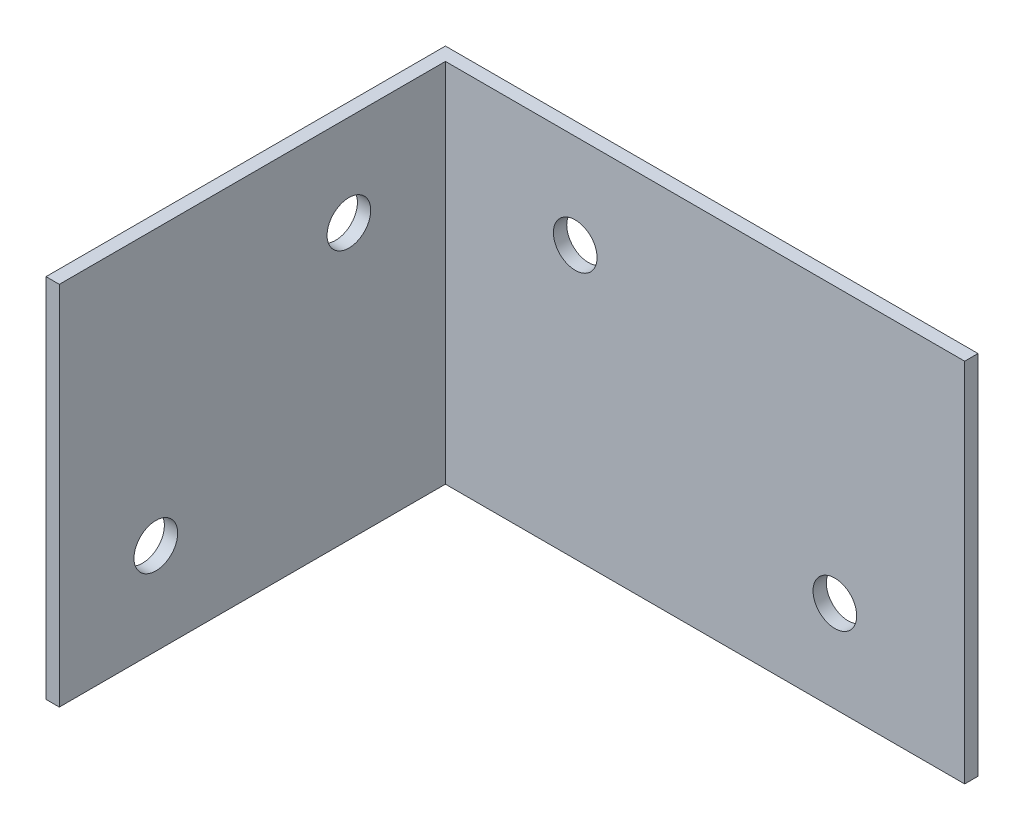
from build123d import *

# Parameters (mm, degrees)
SKETCH1_W           = 50.8
SKETCH1_H           = 34.925
BOSS_EXTRUDE1_DEPTH = 1.27
SKETCH2_W           = 1.27
SKETCH2_H           = 34.925
BOSS_EXTRUDE2_DEPTH = 36.83
SKETCH3_R           = 2.0828
CUT_EXTRUDE1_DEPTH  = 36.83
SKETCH4_R           = 2.0828
CUT_EXTRUDE2_DEPTH  = 36.83


with BuildPart() as part:
    # Sketch1 → Boss-Extrude1 (new body)
    with BuildSketch(Plane.XY):
        Rectangle(SKETCH1_W, SKETCH1_H)
    extrude(amount=BOSS_EXTRUDE1_DEPTH)

    # Sketch2 → Boss-Extrude2 (add)
    with BuildSketch(Plane.XY.offset(1.27)):
        with Locations((-24.765, 0)):
            Rectangle(SKETCH2_W, SKETCH2_H)
    extrude(amount=BOSS_EXTRUDE2_DEPTH)

    # Sketch3 → Cut-Extrude1 (cut)
    with BuildSketch(Plane(origin=(-24.13, 0, 0), x_dir=(0, 0, -1), z_dir=(1, 0, 0))):
        with Locations((-10.4775, 8.73125)):
            Circle(SKETCH3_R)
        with Locations((-28.8925, -8.73125)):
            Circle(SKETCH3_R)
    extrude(amount=-CUT_EXTRUDE1_DEPTH, mode=Mode.SUBTRACT)

    # Sketch4 → Cut-Extrude2 (cut)
    with BuildSketch(Plane.XY.offset(1.27)):
        with Locations((-11.7475, 8.47725)):
            Circle(SKETCH4_R)
        with Locations((13.0175, -8.73125)):
            Circle(SKETCH4_R)
    extrude(amount=-CUT_EXTRUDE2_DEPTH, mode=Mode.SUBTRACT)


solid = part.part
